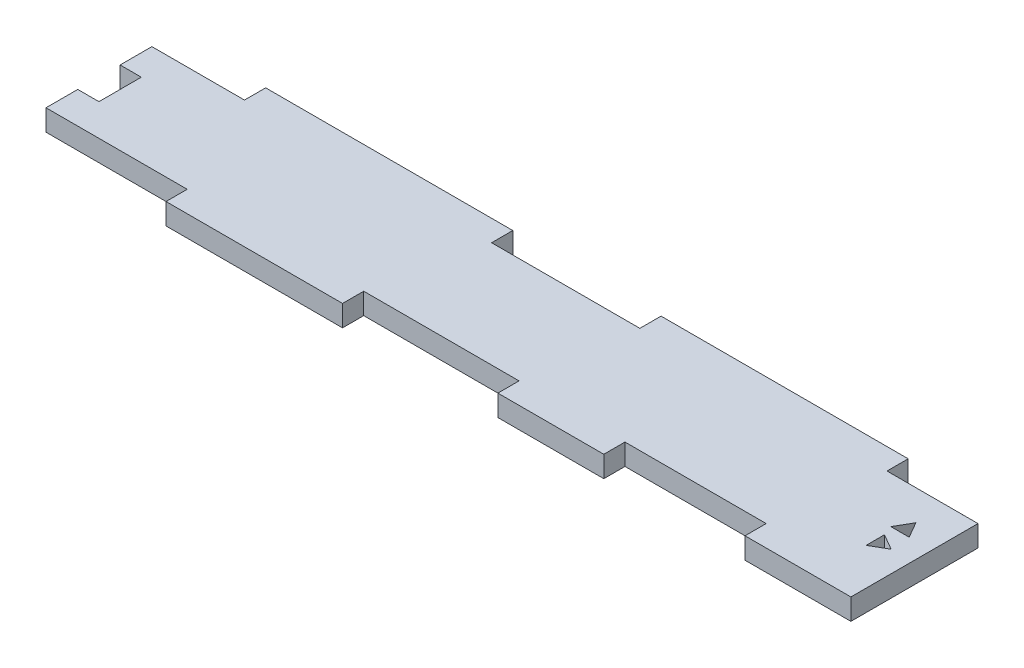
from build123d import *

# Parameters (mm, degrees)
SKETCH1_W                = 117
SKETCH1_H                = 15
BOSS_EXTRUDE1_DEPTH      = 1.5
SKETCH2_W                = 15
SKETCH2_H                = 3
BOSS_EXTRUDE2_DEPTH      = 1.5
SKETCH12_W               = 25
SKETCH12_H               = 3
BOSS_EXTRUDE3_DEPTH      = 1.5
SKETCH13_W               = 35
SKETCH13_H               = 3
BOSS_EXTRUDE4_DEPTH      = 1.5
CUT_EXTRUDE10_DEPTH      = 2.5
CUT_EXTRUDE10_DEPTH_BACK = 2.5
SKETCH16_W               = 3
SKETCH16_H               = 6
CUT_EXTRUDE11_DEPTH      = 2.5
CUT_EXTRUDE11_DEPTH_BACK = 2.5


with BuildPart() as part:
    # Sketch1 → Boss-Extrude1 (new body, symmetric)
    with BuildSketch(Plane(origin=(0, 0, 0), x_dir=(1, 0, 0), z_dir=(0, 1, 0))):
        Rectangle(SKETCH1_W, SKETCH1_H)
    extrude(amount=BOSS_EXTRUDE1_DEPTH, both=True)

    # Sketch2 → Boss-Extrude2 (add, symmetric)
    with BuildSketch(Plane(origin=(0, 0, 0), x_dir=(1, 0, 0), z_dir=(0, 1, 0))):
        with Locations((16, -9)):
            Rectangle(SKETCH2_W, SKETCH2_H)
        with Locations((51, -9)):
            Rectangle(SKETCH2_W, SKETCH2_H)
    extrude(amount=BOSS_EXTRUDE2_DEPTH, both=True)

    # Sketch12 → Boss-Extrude3 (add, symmetric)
    with BuildSketch(Plane(origin=(0, 0, 0), x_dir=(1, 0, 0), z_dir=(0, 1, 0))):
        with Locations((-26, -9)):
            Rectangle(SKETCH12_W, SKETCH12_H)
    extrude(amount=BOSS_EXTRUDE3_DEPTH, both=True)

    # Sketch13 → Boss-Extrude4 (add, symmetric)
    with BuildSketch(Plane(origin=(0, 0, 0), x_dir=(1, 0, 0), z_dir=(0, 1, 0))):
        with Locations((-27.89, 9)):
            Rectangle(SKETCH13_W, SKETCH13_H)
        with Locations((28.11, 9)):
            Rectangle(SKETCH13_W, SKETCH13_H)
    extrude(amount=BOSS_EXTRUDE4_DEPTH, both=True)

    # Sketch15 → Cut-Extrude10 (cut, two sides)
    with BuildSketch(Plane(origin=(0, 0, 0), x_dir=(1, 0, 0), z_dir=(0, 1, 0))) as cut_extrude10_sk:
        Polygon((55.5, -1.799038106), (53.25, -0.5), (53.25, -3.098076211), align=None)
        Polygon((54, 3.202955396), (52.700961894, 0.952955396), (55.299038106, 0.952955396), align=None)
    extrude(amount=CUT_EXTRUDE10_DEPTH, mode=Mode.SUBTRACT)
    extrude(cut_extrude10_sk.sketch, amount=-CUT_EXTRUDE10_DEPTH_BACK, mode=Mode.SUBTRACT)

    # Sketch16 → Cut-Extrude11 (cut, two sides)
    with BuildSketch(Plane(origin=(0, 0, 0), x_dir=(1, 0, 0), z_dir=(0, 1, 0))) as cut_extrude11_sk:
        with Locations((-57, 0)):
            Rectangle(SKETCH16_W, SKETCH16_H)
    extrude(amount=CUT_EXTRUDE11_DEPTH, mode=Mode.SUBTRACT)
    extrude(cut_extrude11_sk.sketch, amount=-CUT_EXTRUDE11_DEPTH_BACK, mode=Mode.SUBTRACT)


solid = part.part
